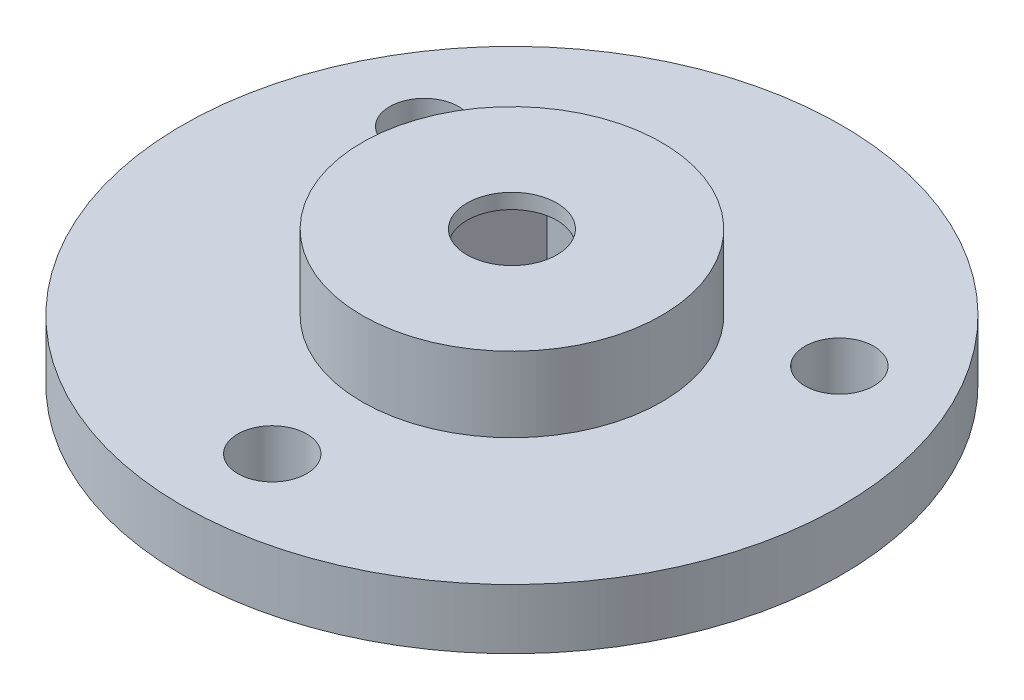
from build123d import *

# Parameters (mm, degrees)
SKETCH1_R           = 11
SKETCH1_R_2         = 1.15
BOSS_EXTRUDE1_DEPTH = 2
SKETCH3_R           = 5
BOSS_EXTRUDE3_DEPTH = 2
SKETCH4_R           = 5
SKETCH4_R_2         = 1.5
BOSS_EXTRUDE4_DEPTH = 0.5


with BuildPart() as part:
    # Sketch1 → Boss-Extrude1 (new body)
    with BuildSketch(Plane(origin=(0, 0, 0), x_dir=(1, 0, 0), z_dir=(0, 1, 0))):
        Circle(SKETCH1_R)
        with Locations((0, -8)):
            Circle(SKETCH1_R_2, mode=Mode.SUBTRACT)
        with Locations((-6.92820323, 4)):
            Circle(SKETCH1_R_2, mode=Mode.SUBTRACT)
        with Locations((6.92820323, 4)):
            Circle(SKETCH1_R_2, mode=Mode.SUBTRACT)
        Polygon((3.175426481, 0), (1.58771324, 2.75), (-1.58771324, 2.75), (-3.175426481, 0), (-1.58771324, -2.75), (1.58771324, -2.75), align=None, mode=Mode.SUBTRACT)
    extrude(amount=BOSS_EXTRUDE1_DEPTH)

    # Sketch3 → Boss-Extrude3 (add, symmetric)
    with BuildSketch(Plane(origin=(0, 2, 0), x_dir=(1, 0, 0), z_dir=(0, 1, 0))):
        Circle(SKETCH3_R)
        Polygon((3.175426481, 0), (1.58771324, 2.75), (-1.58771324, 2.75), (-3.175426481, 0), (-1.58771324, -2.75), (1.58771324, -2.75), align=None, mode=Mode.SUBTRACT)
    extrude(amount=BOSS_EXTRUDE3_DEPTH, both=True)

    # Sketch4 → Boss-Extrude4 (add)
    with BuildSketch(Plane(origin=(0, 4, 0), x_dir=(1, 0, 0), z_dir=(0, 1, 0))):
        Circle(SKETCH4_R)
        Circle(SKETCH4_R_2, mode=Mode.SUBTRACT)
    extrude(amount=BOSS_EXTRUDE4_DEPTH)


solid = part.part
